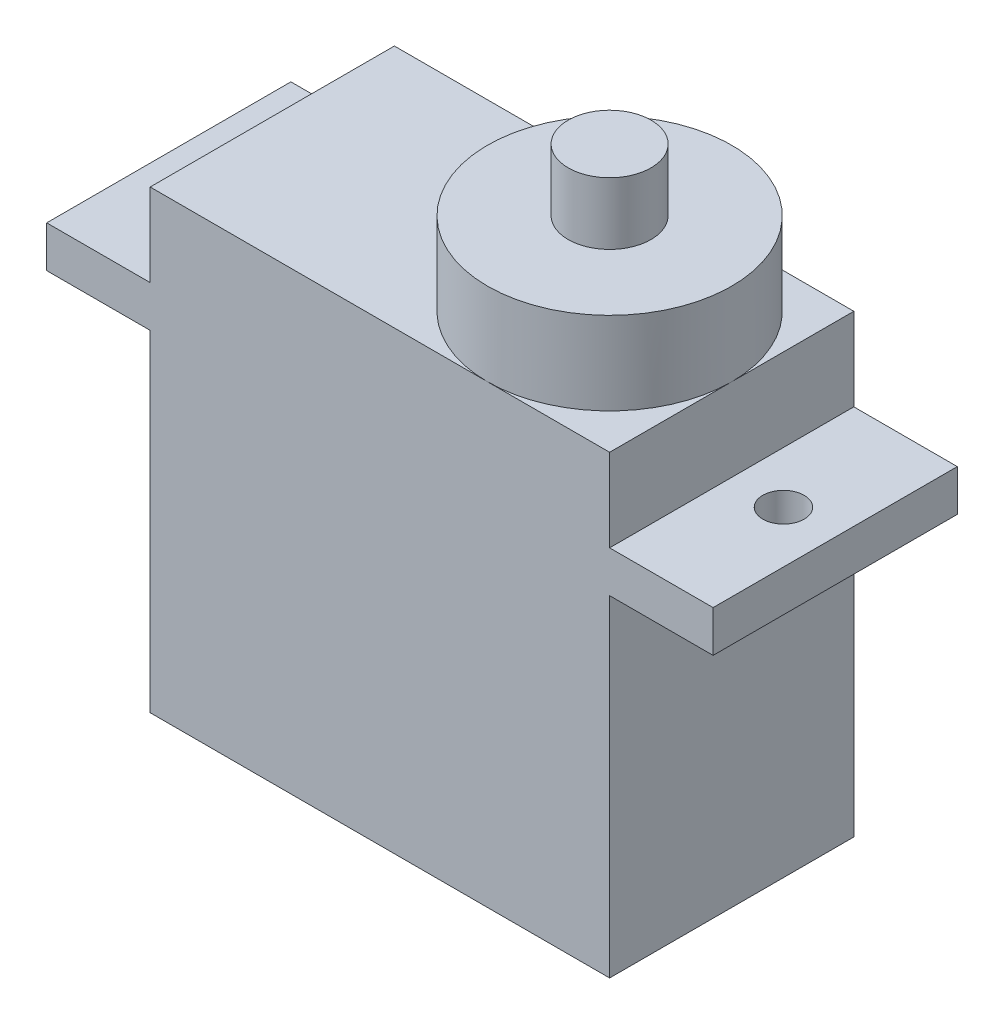
from build123d import *

# Parameters (mm, degrees)
BOSS_EXTRU_1_DEPTH      = 11.8
ESQUISSE2_R             = 1
ENL_V_MAT_EXTRU_1_DEPTH = 11.8
ESQUISSE3_R             = 5.9
BOSS_EXTRU_2_DEPTH      = 4
ESQUISSE4_R             = 2
BOSS_EXTRU_3_DEPTH      = 3
ESQUISSE5_W             = 5
ESQUISSE5_H             = 4
BOSS_EXTRU_4_DEPTH      = 3
ESQUISSE6_W             = 3
ESQUISSE6_H             = 5
ENL_V_MAT_EXTRU_2_DEPTH = 10


with BuildPart() as part:
    # Esquisse1 → Boss.-Extru.1 (new body)
    with BuildSketch(Plane.XY):
        Polygon((-45.196459949, 18), (-40.196459949, 18), (-40.196459949, 22), (-17.996459949, 22), (-17.996459949, 18), (-12.996459949, 18), (-12.996459949, 16), (-17.996459949, 16), (-17.996459949, 0), (-40.196459949, 0), (-40.196459949, 16), (-45.196459949, 16), align=None)
    extrude(amount=BOSS_EXTRU_1_DEPTH)

    # Esquisse2 → Enlèv. mat.-Extru.1 (cut)
    with BuildSketch(Plane(origin=(0, 18, 0), x_dir=(1, 0, 0), z_dir=(0, 1, 0))):
        with Locations((-42.696459949, -5.9)):
            Circle(ESQUISSE2_R)
        with Locations((-15.496459949, -5.9)):
            Circle(ESQUISSE2_R)
    extrude(amount=-ENL_V_MAT_EXTRU_1_DEPTH, mode=Mode.SUBTRACT)

    # Esquisse3 → Boss.-Extru.2 (add)
    with BuildSketch(Plane(origin=(0, 22, 0), x_dir=(1, 0, 0), z_dir=(0, 1, 0))):
        with Locations((-23.896459949, -5.9)):
            Circle(ESQUISSE3_R)
    extrude(amount=BOSS_EXTRU_2_DEPTH)

    # Esquisse4 → Boss.-Extru.3 (add)
    with BuildSketch(Plane(origin=(0, 26, 0), x_dir=(1, 0, 0), z_dir=(0, 1, 0))):
        with Locations((-23.896459949, -5.9)):
            Circle(ESQUISSE4_R)
    extrude(amount=BOSS_EXTRU_3_DEPTH)

    # Esquisse5 → Boss.-Extru.4 (add)
    with BuildSketch(Plane(origin=(-17.996459949, 0, 0), x_dir=(0, 0, -1), z_dir=(1, 0, 0))):
        with Locations((-5.8, 5)):
            Rectangle(ESQUISSE5_W, ESQUISSE5_H)
    extrude(amount=BOSS_EXTRU_4_DEPTH)

    # Esquisse6 → Enlèv. mat.-Extru.2 (cut)
    with BuildSketch(Plane(origin=(0, 7, 0), x_dir=(1, 0, 0), z_dir=(0, 1, 0))):
        with Locations((-16.496459949, -5.8)):
            Rectangle(ESQUISSE6_W, ESQUISSE6_H)
    extrude(amount=-ENL_V_MAT_EXTRU_2_DEPTH, mode=Mode.SUBTRACT)


solid = part.part
